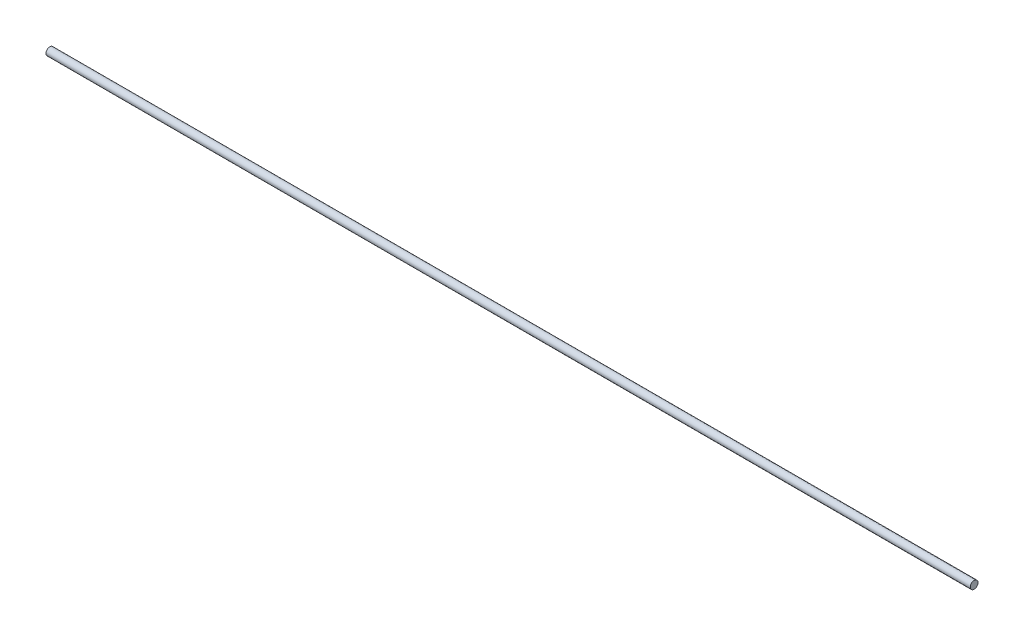
from build123d import *

# Parameters (mm, degrees)
SKETCH1_R           = 3.175
BOSS_EXTRUDE1_DEPTH = 762


with BuildPart() as part:
    # Sketch1 → Boss-Extrude1 (new body)
    with BuildSketch(Plane(origin=(0, 0, 0), x_dir=(0, 0, -1), z_dir=(1, 0, 0))):
        Circle(SKETCH1_R)
    extrude(amount=BOSS_EXTRUDE1_DEPTH)


solid = part.part
